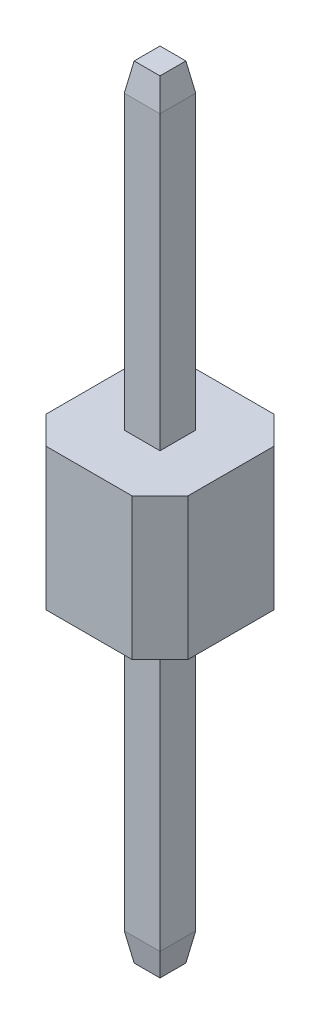
from build123d import *

# Parameters (mm, degrees)
SKETCH1_W                = 2.54
SKETCH1_H                = 2.54
BOSS_EXTRUDE1_DEPTH      = 1.27
BOSS_EXTRUDE1_DEPTH_BACK = 1.27
SKETCH2_W                = 0.64
SKETCH2_H                = 0.64
BOSS_EXTRUDE2_DEPTH      = 7
BOSS_EXTRUDE2_DEPTH_BACK = 7
CHAMFER1_SIZE            = 0.5
CHAMFER1_SIZE2           = 0.08816349
CHAMFER1_PART_2_SIZE     = 0.5
CHAMFER1_PART_2_SIZE2    = 0.08816349
CHAMFER1_PART_3_SIZE     = 0.5
CHAMFER1_PART_3_SIZE2    = 0.08816349
CHAMFER1_PART_4_SIZE     = 0.5
CHAMFER1_PART_4_SIZE2    = 0.08816349
CHAMFER1_PART_5_SIZE     = 0.5
CHAMFER1_PART_5_SIZE2    = 0.08816349
CHAMFER1_PART_6_SIZE     = 0.5
CHAMFER1_PART_6_SIZE2    = 0.08816349
CHAMFER1_PART_7_SIZE     = 0.5
CHAMFER1_PART_7_SIZE2    = 0.08816349
CHAMFER1_PART_8_SIZE     = 0.5
CHAMFER1_PART_8_SIZE2    = 0.08816349
CHAMFER2_SIZE            = 0.5


with BuildPart() as part:
    # Sketch1 → Boss-Extrude1 (new body, two sides)
    with BuildSketch(Plane(origin=(0, 0, 0), x_dir=(1, 0, 0), z_dir=(0, 1, 0))) as boss_extrude1_sk:
        Rectangle(SKETCH1_W, SKETCH1_H)
    extrude(amount=BOSS_EXTRUDE1_DEPTH)
    extrude(boss_extrude1_sk.sketch, amount=-BOSS_EXTRUDE1_DEPTH_BACK)

    # Sketch2 → Boss-Extrude2 (add, two sides)
    with BuildSketch(Plane(origin=(0, 0, 0), x_dir=(1, 0, 0), z_dir=(0, 1, 0))) as boss_extrude2_sk:
        Rectangle(SKETCH2_W, SKETCH2_H)
    extrude(amount=BOSS_EXTRUDE2_DEPTH)
    extrude(boss_extrude2_sk.sketch, amount=-BOSS_EXTRUDE2_DEPTH_BACK)

    # Chamfer1
    chamfer1_edges = [part.edges().sort_by_distance(p)[0] for p in [
        (-0.32, -7, 0),
    ]]
    chamfer1_side = [part.faces().sort_by_distance(p)[0] for p in [
        (-0.32, -4.135, 0),
    ]]
    chamfer(chamfer1_edges, length=CHAMFER1_SIZE, length2=CHAMFER1_SIZE2, reference=chamfer1_side[0])

    # Chamfer1 part 2
    chamfer1_part_2_edges = [part.edges().sort_by_distance(p)[0] for p in [
        (0, -7, -0.32),
    ]]
    chamfer1_part_2_side = [part.faces().sort_by_distance(p)[0] for p in [
        (0, -4.135, -0.32),
    ]]
    chamfer(chamfer1_part_2_edges, length=CHAMFER1_PART_2_SIZE, length2=CHAMFER1_PART_2_SIZE2, reference=chamfer1_part_2_side[0])

    # Chamfer1 part 3
    chamfer1_part_3_edges = [part.edges().sort_by_distance(p)[0] for p in [
        (0.32, -7, 0),
    ]]
    chamfer1_part_3_side = [part.faces().sort_by_distance(p)[0] for p in [
        (0.32, -4.135, 0),
    ]]
    chamfer(chamfer1_part_3_edges, length=CHAMFER1_PART_3_SIZE, length2=CHAMFER1_PART_3_SIZE2, reference=chamfer1_part_3_side[0])

    # Chamfer1 part 4
    chamfer1_part_4_edges = [part.edges().sort_by_distance(p)[0] for p in [
        (0, -7, 0.32),
    ]]
    chamfer1_part_4_side = [part.faces().sort_by_distance(p)[0] for p in [
        (0, -4.135, 0.32),
    ]]
    chamfer(chamfer1_part_4_edges, length=CHAMFER1_PART_4_SIZE, length2=CHAMFER1_PART_4_SIZE2, reference=chamfer1_part_4_side[0])

    # Chamfer1 part 5
    chamfer1_part_5_edges = [part.edges().sort_by_distance(p)[0] for p in [
        (-0.32, 7, 0),
    ]]
    chamfer1_part_5_side = [part.faces().sort_by_distance(p)[0] for p in [
        (-0.32, 4.135, 0),
    ]]
    chamfer(chamfer1_part_5_edges, length=CHAMFER1_PART_5_SIZE, length2=CHAMFER1_PART_5_SIZE2, reference=chamfer1_part_5_side[0])

    # Chamfer1 part 6
    chamfer1_part_6_edges = [part.edges().sort_by_distance(p)[0] for p in [
        (0, 7, 0.32),
    ]]
    chamfer1_part_6_side = [part.faces().sort_by_distance(p)[0] for p in [
        (0, 4.135, 0.32),
    ]]
    chamfer(chamfer1_part_6_edges, length=CHAMFER1_PART_6_SIZE, length2=CHAMFER1_PART_6_SIZE2, reference=chamfer1_part_6_side[0])

    # Chamfer1 part 7
    chamfer1_part_7_edges = [part.edges().sort_by_distance(p)[0] for p in [
        (0.32, 7, 0),
    ]]
    chamfer1_part_7_side = [part.faces().sort_by_distance(p)[0] for p in [
        (0.32, 4.135, 0),
    ]]
    chamfer(chamfer1_part_7_edges, length=CHAMFER1_PART_7_SIZE, length2=CHAMFER1_PART_7_SIZE2, reference=chamfer1_part_7_side[0])

    # Chamfer1 part 8
    chamfer1_part_8_edges = [part.edges().sort_by_distance(p)[0] for p in [
        (0, 7, -0.32),
    ]]
    chamfer1_part_8_side = [part.faces().sort_by_distance(p)[0] for p in [
        (0, 4.135, -0.32),
    ]]
    chamfer(chamfer1_part_8_edges, length=CHAMFER1_PART_8_SIZE, length2=CHAMFER1_PART_8_SIZE2, reference=chamfer1_part_8_side[0])

    # Chamfer2
    chamfer2_edges = [part.edges().sort_by_distance(p)[0] for p in [
        (-1.27, 0, -1.27),
        (1.27, 0, -1.27),
        (1.27, 0, 1.27),
        (-1.27, 0, 1.27),
    ]]
    chamfer(chamfer2_edges, length=CHAMFER2_SIZE)


solid = part.part
